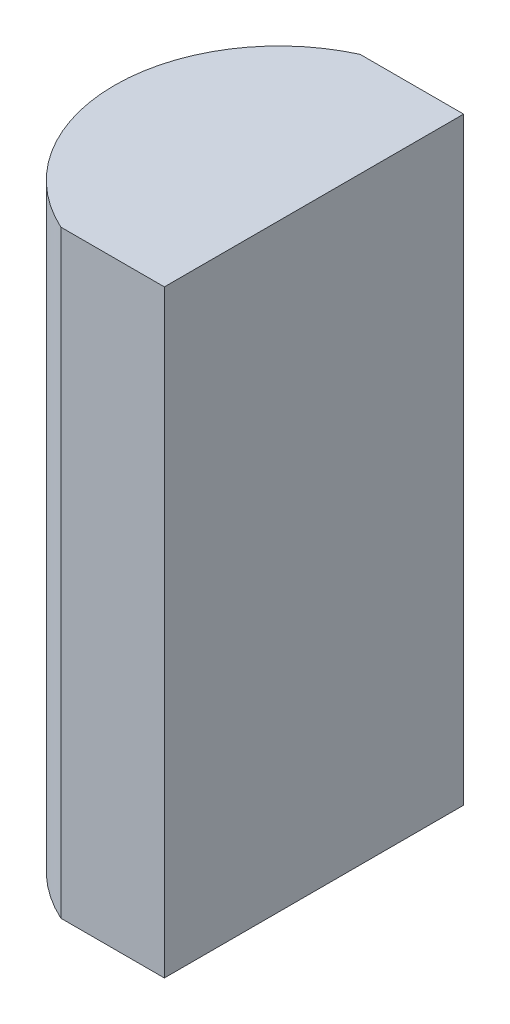
from build123d import *

# Parameters (mm, degrees)
EXTRUDE_1_DEPTH = 12


with BuildPart() as part:
    # 草图1 → 凸台-拉伸1 (new body)
    with BuildSketch(Plane(origin=(0, 0, 0), x_dir=(1, 0, 0), z_dir=(0, 1, 0))):
        with BuildLine():
            Line((2.980431626, 3), (5.055204335, 3))
            Line((5.055204335, 3), (5.055204335, -3))
            Line((5.055204335, -3), (2.980431626, -3))
            ThreePointArc((2.980431626, -3), (1.055204335, 0), (2.980431626, 3))
        make_face()
    extrude(amount=EXTRUDE_1_DEPTH)


solid = part.part
